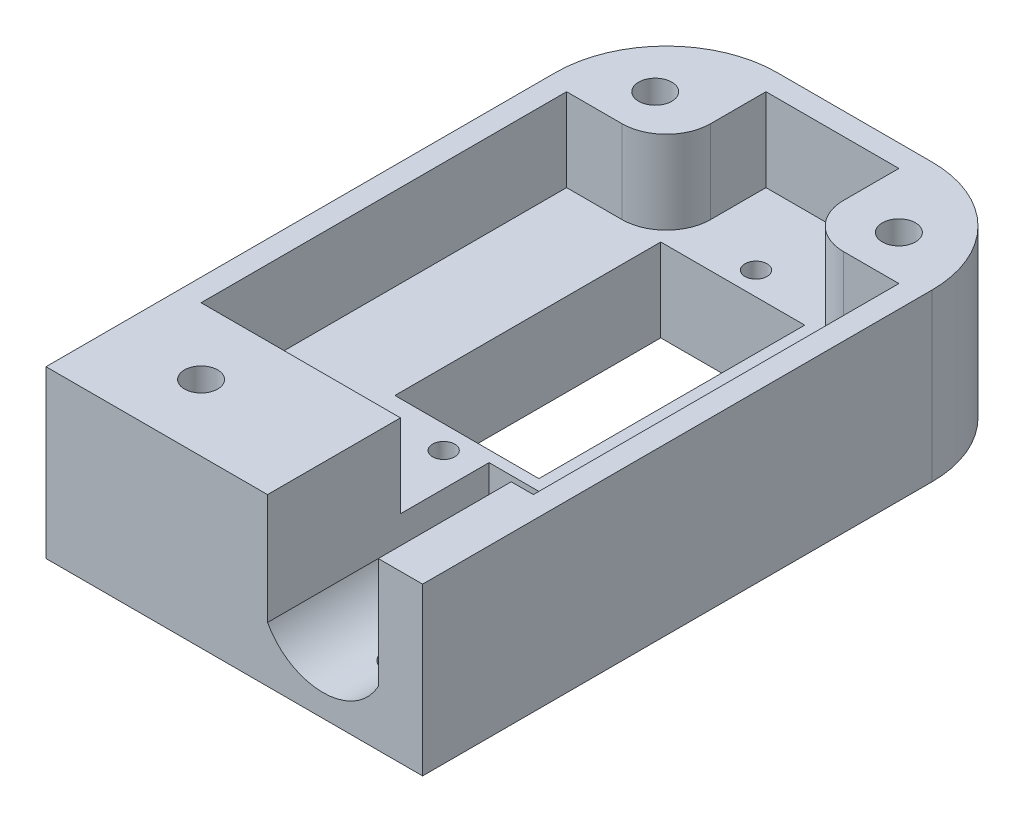
from build123d import *

# Parameters (mm, degrees)
SKETCH1_R           = 1.5
BOSS_EXTRUDE3_DEPTH = 15
SKETCH3_R           = 1.5
CUT_EXTRUDE1_DEPTH  = 7.5
SKETCH5_W           = 13
SKETCH5_H           = 24
CUT_EXTRUDE2_DEPTH  = 10
SKETCH6_R           = 1
CUT_EXTRUDE3_DEPTH  = 10
SKETCH8_R           = 5.15
CUT_EXTRUDE4_DEPTH  = 15
SKETCH9_W           = 3
SKETCH9_H           = 13
CUT_EXTRUDE5_DEPTH  = 55.899908925
FILLET2_R           = 2
SKETCH10_W          = 6
SKETCH10_H          = 1.8
CUT_EXTRUDE6_DEPTH  = 55.899908925
SKETCH11_R          = 0.75
CUT_EXTRUDE7_DEPTH  = 10
SKETCH13_R          = 1.5
CUT_EXTRUDE8_DEPTH  = 55.899908925
SKETCH14_R          = 3
CUT_EXTRUDE9_DEPTH  = 5
SKETCH15_W          = 9
SKETCH15_H          = 15
SKETCH15_R          = 1.15
BOSS_EXTRUDE4_DEPTH = 2
SKETCH16_W          = 31.135337716
SKETCH16_H          = 16.721473769
CUT_EXTRUDE10_DEPTH = 55.899908925
CUT_EXTRUDE11_DEPTH = 20


with BuildPart() as part:
    # Sketch1 → Boss-Extrude3 (new body)
    with BuildSketch(Plane(origin=(0, 0, 0), x_dir=(1, 0, 0), z_dir=(0, 1, 0))):
        with BuildLine():
            Line((17, 40), (17, -19))
            Line((17, -19), (-17, -19))
            Line((-17, -19), (-17, 40))
            ThreePointArc((-17, 40), (-14.071067812, 47.071067812), (-7, 50))
            Line((-7, 50), (7, 50))
            ThreePointArc((7, 50), (14.071067812, 47.071067812), (17, 40))
        make_face()
        with Locations((-9, 0)):
            Circle(SKETCH1_R, mode=Mode.SUBTRACT)
        with Locations((9, 0)):
            Circle(SKETCH1_R, mode=Mode.SUBTRACT)
    extrude(amount=BOSS_EXTRUDE3_DEPTH)

    # Sketch3 → Cut-Extrude1 (cut)
    with BuildSketch(Plane(origin=(0, 15, 0), x_dir=(1, 0, 0), z_dir=(0, 1, 0))):
        with BuildLine():
            Line((6, 43), (6, 48))
            Line((6, 48), (-6, 48))
            Line((-6, 48), (-6, 43))
            ThreePointArc((-6, 43), (-7.171572875, 40.171572875), (-10, 39))
            Line((-10, 39), (-15, 39))
            Line((-15, 39), (-15, 6))
            Line((-15, 6), (15, 6))
            Line((15, 6), (15, 39))
            Line((15, 39), (10, 39))
            ThreePointArc((10, 39), (7.171572875, 40.171572875), (6, 43))
        make_face()
        with Locations((-11, 43)):
            Circle(SKETCH3_R)
        with Locations((11, 43)):
            Circle(SKETCH3_R)
    extrude(amount=-CUT_EXTRUDE1_DEPTH, mode=Mode.SUBTRACT)

    # Sketch5 → Cut-Extrude2 (cut)
    with BuildSketch(Plane(origin=(0, 7.5, 0), x_dir=(1, 0, 0), z_dir=(0, 1, 0))):
        with Locations((0, 27)):
            Rectangle(SKETCH5_W, SKETCH5_H)
    extrude(amount=-CUT_EXTRUDE2_DEPTH, mode=Mode.SUBTRACT)

    # Sketch6 → Cut-Extrude3 (cut)
    with BuildSketch(Plane(origin=(0, 7.5, 0), x_dir=(1, 0, 0), z_dir=(0, 1, 0))):
        with Locations((0, 41.1)):
            Circle(SKETCH6_R)
        with Locations((0, 12.9)):
            Circle(SKETCH6_R)
    extrude(amount=-CUT_EXTRUDE3_DEPTH, mode=Mode.SUBTRACT)

    # Sketch8 → Cut-Extrude4 (cut)
    with BuildSketch(Plane(origin=(0, 15, 0), x_dir=(1, 0, 0), z_dir=(0, 1, 0))):
        with Locations((-6, -12)):
            Circle(SKETCH8_R)
        with Locations((6, -12)):
            Circle(SKETCH8_R)
    extrude(amount=-CUT_EXTRUDE4_DEPTH, mode=Mode.SUBTRACT)

    # Sketch9 → Cut-Extrude5 (cut, through all)
    with BuildSketch(Plane(origin=(0, 15, 0), x_dir=(1, 0, 0), z_dir=(0, 1, 0))):
        with Locations((15.5, -12.5)):
            Rectangle(SKETCH9_W, SKETCH9_H)
        with Locations((-15.5, -12.5)):
            Rectangle(SKETCH9_W, SKETCH9_H)
    extrude(amount=-CUT_EXTRUDE5_DEPTH, mode=Mode.SUBTRACT)

    # Fillet2
    fillet2_edges = [part.edges().sort_by_distance(p)[0] for p in [
        (-14, 7.5, 19),
        (14, 7.5, 19),
    ]]
    fillet(fillet2_edges, radius=FILLET2_R)

    # Sketch10 → Cut-Extrude6 (cut, through all)
    with BuildSketch(Plane(origin=(0, 15, 0), x_dir=(1, 0, 0), z_dir=(0, 1, 0))):
        with Locations((0, -18.1)):
            Rectangle(SKETCH10_W, SKETCH10_H)
    extrude(amount=-CUT_EXTRUDE6_DEPTH, mode=Mode.SUBTRACT)

    # Sketch11 → Cut-Extrude7 (cut)
    with BuildSketch(Plane.XY.offset(17.2)):
        with Locations((0, 7.5)):
            Circle(SKETCH11_R)
    extrude(amount=-CUT_EXTRUDE7_DEPTH, mode=Mode.SUBTRACT)

    # Sketch13 → Cut-Extrude8 (cut, through all)
    with BuildSketch(Plane(origin=(0, 15, 0), x_dir=(1, 0, 0), z_dir=(0, 1, 0))):
        with Locations((11, 43)):
            Circle(SKETCH13_R)
        with Locations((-11, 43)):
            Circle(SKETCH13_R)
    extrude(amount=-CUT_EXTRUDE8_DEPTH, mode=Mode.SUBTRACT)

    # Sketch14 → Cut-Extrude9 (cut)
    with BuildSketch(Plane.XZ):
        with Locations((11, -43)):
            Circle(SKETCH14_R)
        with Locations((-11, -43)):
            Circle(SKETCH14_R)
    extrude(amount=-CUT_EXTRUDE9_DEPTH, mode=Mode.SUBTRACT)

    # Sketch15 → Boss-Extrude4 (add)
    with BuildSketch(Plane.XY.offset(19)):
        with Locations((7.5, 7.5)):
            Rectangle(SKETCH15_W, SKETCH15_H)
        with Locations((8, 12)):
            Circle(SKETCH15_R, mode=Mode.SUBTRACT)
    extrude(amount=BOSS_EXTRUDE4_DEPTH)

    # Sketch16 → Cut-Extrude10 (cut, through all)
    with BuildSketch(Plane(origin=(0, 15, 0), x_dir=(1, 0, 0), z_dir=(0, 1, 0))):
        with Locations((1.567668858, -14.360736885)):
            Rectangle(SKETCH16_W, SKETCH16_H)
    extrude(amount=-CUT_EXTRUDE10_DEPTH, mode=Mode.SUBTRACT)

    # Sketch19 → Cut-Extrude11 (cut)
    with BuildSketch(Plane.XY.offset(6)):
        with BuildLine():
            Line((3, 15), (13, 15))
            Line((13, 15), (13, 5))
            ThreePointArc((13, 5), (8, 2.022346613), (3, 5))
            Line((3, 5), (3, 15))
        make_face()
    extrude(amount=-CUT_EXTRUDE11_DEPTH, mode=Mode.SUBTRACT)


solid = part.part
